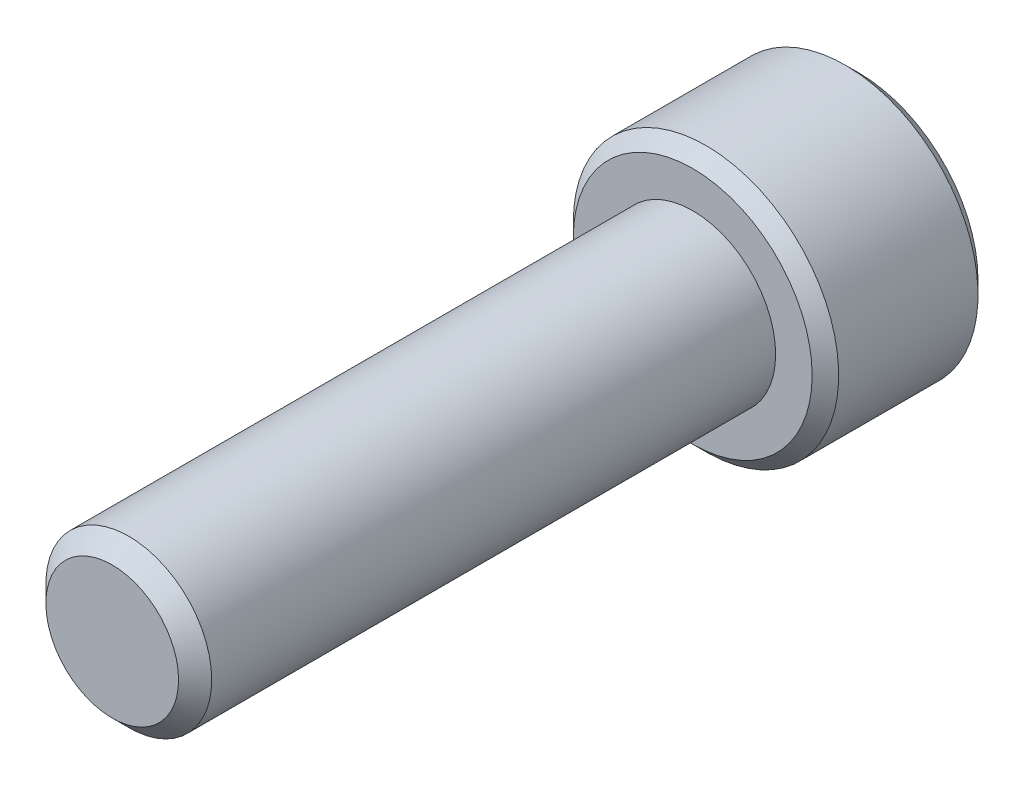
from build123d import *

# Parameters (mm, degrees)
SKETCH1_R          = 5
EXTRUDE1_DEPTH     = 35
SKETCH6_R          = 8
EXTRUDE2_DEPTH     = 10
CUT_EXTRUDE1_DEPTH = 6
CHAMFER1_SIZE      = 0.8
CHAMFER2_SIZE      = 1


with BuildPart() as part:
    # Sketch1 → Extrude1 (new body)
    with BuildSketch(Plane.XY):
        Circle(SKETCH1_R)
    extrude(amount=-EXTRUDE1_DEPTH)

    # Sketch6 → Extrude2 (add)
    with BuildSketch(Plane(origin=(0, 0, -35), x_dir=(-1, 0, 0), z_dir=(0, 0, -1))):
        Circle(SKETCH6_R)
    extrude(amount=EXTRUDE2_DEPTH)

    # Sketch7 → Cut-Extrude1 (cut)
    with BuildSketch(Plane(origin=(0, 0, -45), x_dir=(-1, 0, 0), z_dir=(0, 0, -1))):
        Polygon((0, 4.618802154), (-4, 2.309401077), (-4, -2.309401077), (0, -4.618802154), (4, -2.309401077), (4, 2.309401077), align=None)
    extrude(amount=-CUT_EXTRUDE1_DEPTH, mode=Mode.SUBTRACT)

    # Cut-Extrude2 cone 1 section (through the dimple's axis) → Cut-Extrude2 (revolve, cut)
    with BuildSketch(Plane(origin=(0, 0, -45), x_dir=(0, 1, 0), z_dir=(1, 0, 0))):
        Polygon((0, 0), (4.618802154, 0), (0, 4.618802154), align=None)
    revolve(axis=Axis((0, 0, -45), (0, 0, 1)), mode=Mode.SUBTRACT)

    # Chamfer1
    chamfer1_edges = [part.edges().sort_by_distance(p)[0] for p in [
        (8, 0, -35),
        (8, 0, -45),
    ]]
    chamfer(chamfer1_edges, length=CHAMFER1_SIZE)

    # Chamfer2
    chamfer2_edges = [part.edges().sort_by_distance(p)[0] for p in [
        (-5, 0, 0),
    ]]
    chamfer(chamfer2_edges, length=CHAMFER2_SIZE)


solid = part.part
